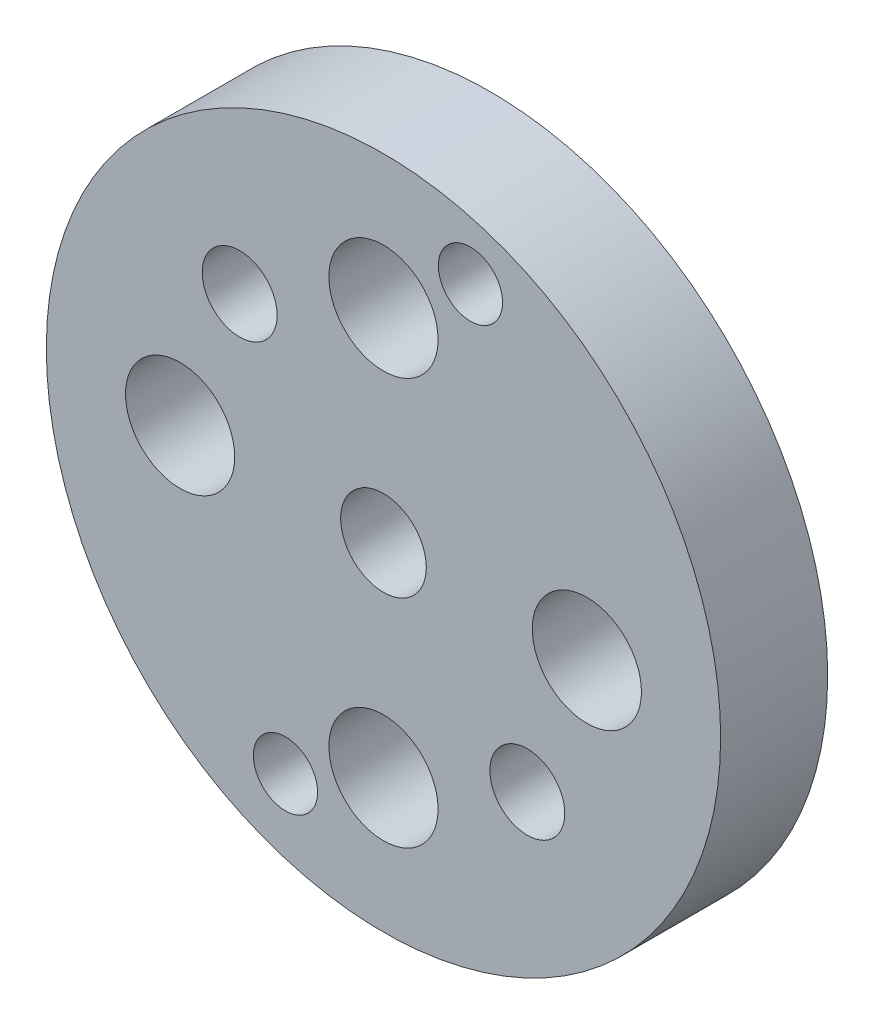
from build123d import *

# Parameters (mm, degrees)
SKETCH1_R           = 31.5
SKETCH1_R_2         = 3.000009018
SKETCH1_R_3         = 5.1
SKETCH1_R_4         = 3.5
SKETCH1_R_5         = 3
SKETCH1_R_6         = 4
BOSS_EXTRUDE1_DEPTH = 10
SKETCH1_3_R         = 5.1
SKETCH1_3_R_2       = 3.5
SKETCH1_3_R_3       = 3
SKETCH1_3_R_4       = 2.5
SKETCH1_3_R_5       = 3.000009018
BOSS_EXTRUDE2_DEPTH = 2


with BuildPart() as part:
    # Sketch1 → Boss-Extrude1 (new body)
    with BuildSketch(Plane.XY):
        Circle(SKETCH1_R)
        with Locations((-9.156294472, -23.262894737)):
            Circle(SKETCH1_R_2, mode=Mode.SUBTRACT)
        with Locations((0, 19)):
            Circle(SKETCH1_R_3, mode=Mode.SUBTRACT)
        with Locations((-13.436536842, 13.433520674)):
            Circle(SKETCH1_R_4, mode=Mode.SUBTRACT)
        with Locations((-19, 0)):
            Circle(SKETCH1_R_3, mode=Mode.SUBTRACT)
        with Locations((0, -19)):
            Circle(SKETCH1_R_3, mode=Mode.SUBTRACT)
        with Locations((13.436536842, -13.433520674)):
            Circle(SKETCH1_R_4, mode=Mode.SUBTRACT)
        with Locations((19, 0)):
            Circle(SKETCH1_R_3, mode=Mode.SUBTRACT)
        with Locations((8.124653839, 25)):
            Circle(SKETCH1_R_5, mode=Mode.SUBTRACT)
        Circle(SKETCH1_R_6, mode=Mode.SUBTRACT)
    extrude(amount=BOSS_EXTRUDE1_DEPTH)

    # Sketch1_3 → Boss-Extrude2 (add)
    # profile 1 of 8: a face of its own
    with BuildSketch(Plane.XY):
        with Locations((19, 0)):
            Circle(SKETCH1_3_R)
        with Locations((19, 0)):
            Circle(SKETCH1_3_R_2, mode=Mode.SUBTRACT)
    # profile 2 of 8: a face of its own
    with BuildSketch(Plane.XY):
        with Locations((0, 19)):
            Circle(SKETCH1_3_R)
        with Locations((0, 19)):
            Circle(SKETCH1_3_R_2, mode=Mode.SUBTRACT)
    # profile 3 of 8: a face of its own
    with BuildSketch(Plane.XY):
        with Locations((13.436536842, -13.433520674)):
            Circle(SKETCH1_3_R_2)
        with Locations((13.436536842, -13.433520674)):
            Circle(SKETCH1_3_R_3, mode=Mode.SUBTRACT)
    # profile 4 of 8: a face of its own
    with BuildSketch(Plane.XY):
        with Locations((-13.436536842, 13.433520674)):
            Circle(SKETCH1_3_R_2)
        with Locations((-13.436536842, 13.433520674)):
            Circle(SKETCH1_3_R_3, mode=Mode.SUBTRACT)
    # profile 5 of 8: a face of its own
    with BuildSketch(Plane.XY):
        with Locations((0, -19)):
            Circle(SKETCH1_3_R)
        with Locations((0, -19)):
            Circle(SKETCH1_3_R_2, mode=Mode.SUBTRACT)
    # profile 6 of 8: a face of its own
    with BuildSketch(Plane.XY):
        with Locations((-19, 0)):
            Circle(SKETCH1_3_R)
        with Locations((-19, 0)):
            Circle(SKETCH1_3_R_2, mode=Mode.SUBTRACT)
    # profile 7 of 8: a face of its own
    with BuildSketch(Plane.XY):
        with Locations((8.124653839, 25)):
            Circle(SKETCH1_3_R_3)
        with Locations((8.124653839, 25)):
            Circle(SKETCH1_3_R_4, mode=Mode.SUBTRACT)
    # profile 8 of 8: a face of its own
    with BuildSketch(Plane.XY):
        with Locations((-9.156294472, -23.262894737)):
            Circle(SKETCH1_3_R_5)
        with Locations((-9.156294472, -23.262894737)):
            Circle(SKETCH1_3_R_4, mode=Mode.SUBTRACT)
    extrude(amount=BOSS_EXTRUDE2_DEPTH)


solid = part.part
